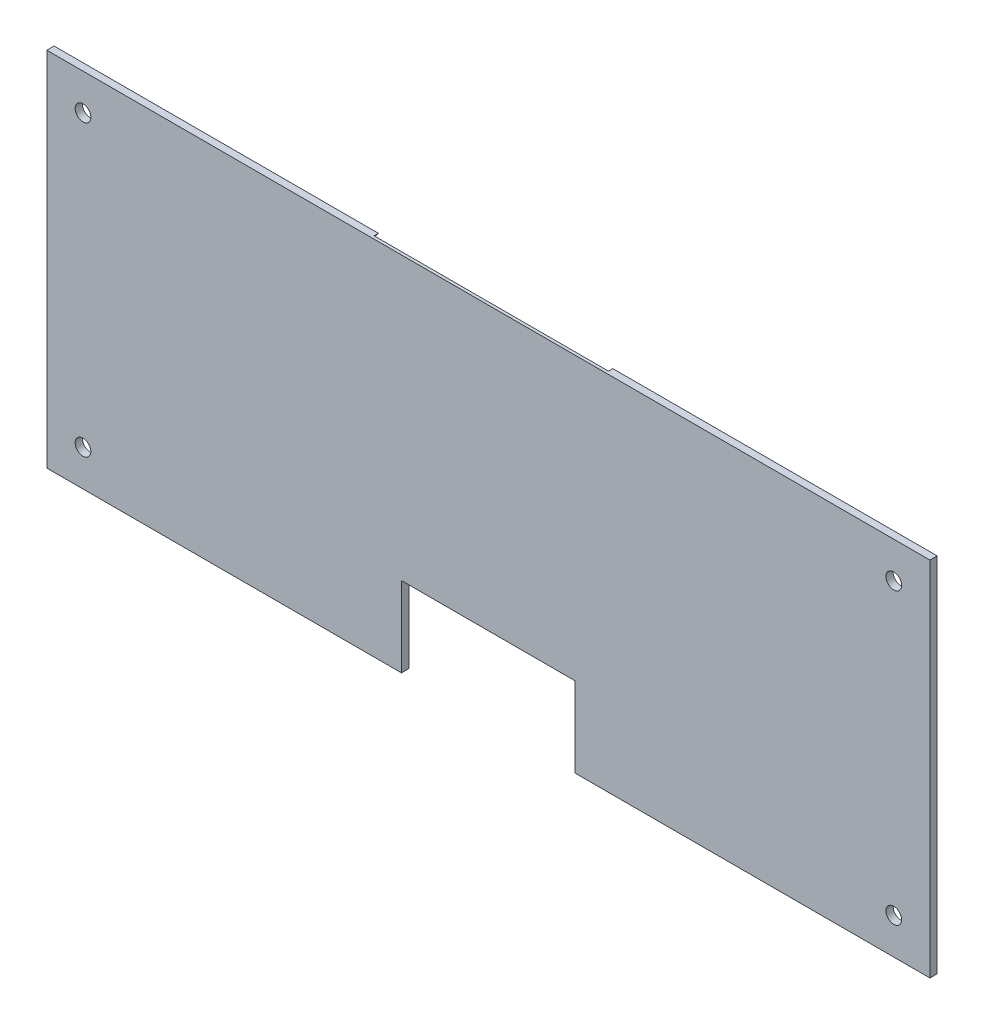
from build123d import *

# Parameters (mm, degrees)
SKETCH1_R           = 3.429
BOSS_EXTRUDE1_DEPTH = 3.175
SKETCH3_R           = 67.945
CUT_EXTRUDE2_DEPTH  = 1.905


with BuildPart() as part:
    # Sketch1 → Boss-Extrude1 (new body)
    with BuildSketch(Plane.XY):
        Polygon((38.1, -79.375), (193.675, -79.375), (193.675, 79.375), (-193.675, 79.375), (-193.675, -79.375), (-38.1, -79.375), (-38.1, -44.323), (38.1, -44.323), align=None)
        with Locations((-177.8, 63.5)):
            Circle(SKETCH1_R, mode=Mode.SUBTRACT)
        with Locations((177.8, 63.5)):
            Circle(SKETCH1_R, mode=Mode.SUBTRACT)
        with Locations((177.8, -63.5)):
            Circle(SKETCH1_R, mode=Mode.SUBTRACT)
        with Locations((-177.8, -63.5)):
            Circle(SKETCH1_R, mode=Mode.SUBTRACT)
    extrude(amount=BOSS_EXTRUDE1_DEPTH)

    # Sketch3 → Cut-Extrude2 (cut)
    with BuildSketch(Plane(origin=(0, 0, 0), x_dir=(-1, 0, 0), z_dir=(0, 0, -1))):
        with Locations((0, 34.925)):
            Circle(SKETCH3_R)
    extrude(amount=-CUT_EXTRUDE2_DEPTH, mode=Mode.SUBTRACT)


solid = part.part
